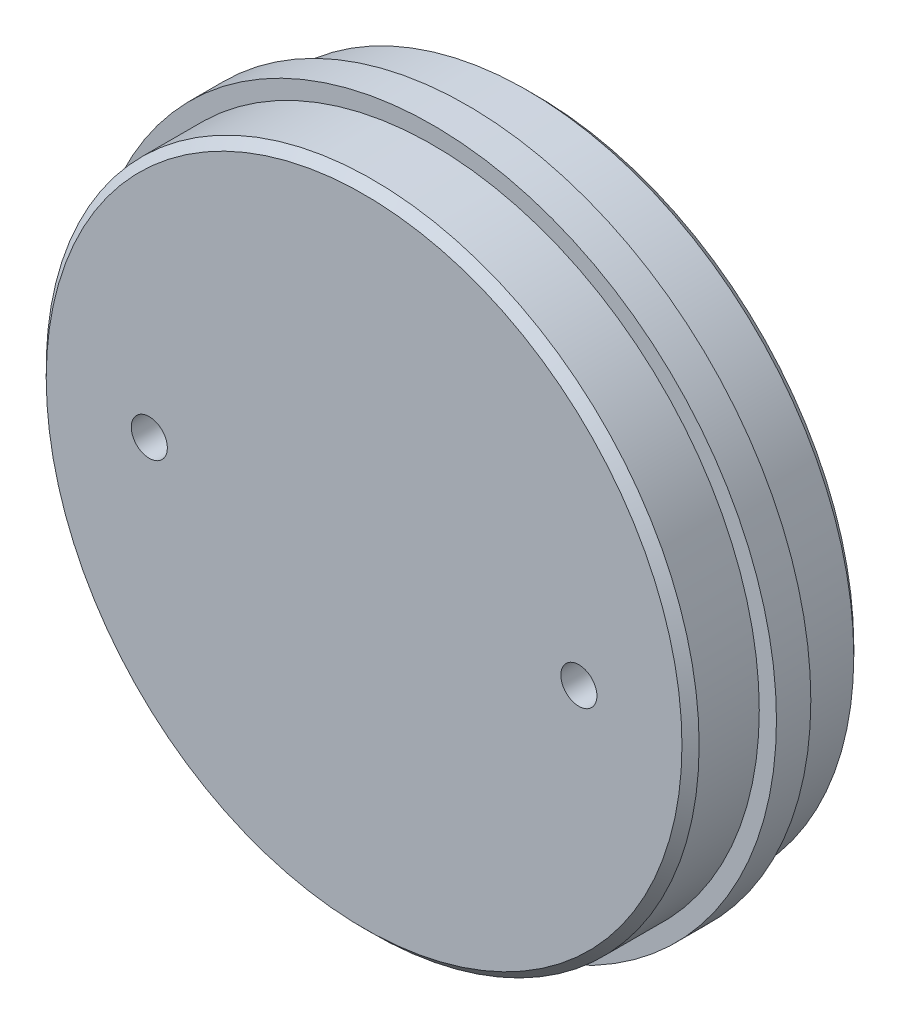
from build123d import *

# Parameters (mm, degrees)
ESQUISSE1_R             = 40
BOSS_EXTRU_1_DEPTH      = 4
ESQUISSE2_R             = 38
BOSS_EXTRU_2_DEPTH      = 8
BOSS_EXTRU_2_DEPTH_BACK = 12
CHANFREIN1_SIZE         = 1
ESQUISSE3_R             = 2.1
ENL_V_MAT_EXTRU_1_DEPTH = 21


with BuildPart() as part:
    # Esquisse1 → Boss.-Extru.1 (new body)
    with BuildSketch(Plane.XY):
        Circle(ESQUISSE1_R)
    extrude(amount=BOSS_EXTRU_1_DEPTH)

    # Esquisse2 → Boss.-Extru.2 (add, two sides)
    with BuildSketch(Plane.XY.offset(4)) as boss_extru_2_sk:
        Circle(ESQUISSE2_R)
    extrude(amount=BOSS_EXTRU_2_DEPTH)
    extrude(boss_extru_2_sk.sketch, amount=-BOSS_EXTRU_2_DEPTH_BACK)

    # Chanfrein1
    chanfrein1_edges = [part.edges().sort_by_distance(p)[0] for p in [
        (-38, 0, -8),
        (-38, 0, 12),
    ]]
    chamfer(chanfrein1_edges, length=CHANFREIN1_SIZE)

    # Esquisse3 → Enlèv. mat.-Extru.1 (cut, through all)
    with BuildSketch(Plane.XY.offset(12)):
        with Locations((25, 0)):
            Circle(ESQUISSE3_R)
        with Locations((-25, 0)):
            Circle(ESQUISSE3_R)
    extrude(amount=-ENL_V_MAT_EXTRU_1_DEPTH, mode=Mode.SUBTRACT)


solid = part.part
